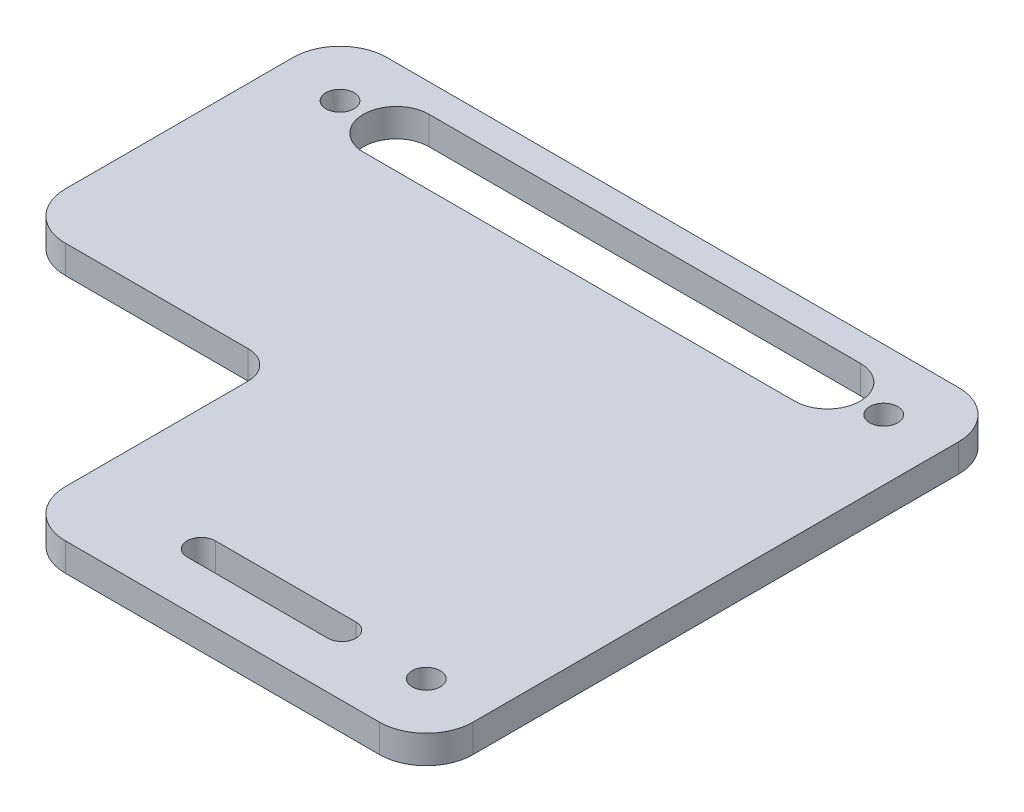
from build123d import *

# Parameters (mm, degrees)
SKETCH_1_W          = 71
SKETCH_1_H          = 61.8
EXTRUDE_1_DEPTH     = 3
FILLET_1_R          = 5
FILLET_3_R          = 5
FILLET_4_R          = 5
SKETCH_2_R          = 1.5
CUT_EXTRUDE_1_DEPTH = 4
CUT_EXTRUDE_2_DEPTH = 4
SKETCH_6_W          = 27.5
SKETCH_6_H          = 27.5
CUT_EXTRUDE_3_DEPTH = 4
FILLET_5_R          = 5
FILLET_6_R          = 3
CUT_EXTRUDE_4_DEPTH = 4


with BuildPart() as part:
    # 草图1 → 凸台-拉伸1 (new body)
    with BuildSketch(Plane(origin=(0, 0, 0), x_dir=(1, 0, 0), z_dir=(0, 1, 0))):
        with Locations((-1.407488987, -9.162114537)):
            Rectangle(SKETCH_1_W, SKETCH_1_H)
    extrude(amount=EXTRUDE_1_DEPTH)

    # 圆角1
    fillet_1_edges = [part.edges().sort_by_distance(p)[0] for p in [
        (-36.907488987, 1.5, -21.737885463),
    ]]
    fillet(fillet_1_edges, radius=FILLET_1_R)

    # 圆角3
    fillet_3_edges = [part.edges().sort_by_distance(p)[0] for p in [
        (34.092511013, 1.5, 40.062114537),
    ]]
    fillet(fillet_3_edges, radius=FILLET_3_R)

    # 圆角4
    fillet_4_edges = [part.edges().sort_by_distance(p)[0] for p in [
        (34.092511013, 1.5, -21.737885463),
    ]]
    fillet(fillet_4_edges, radius=FILLET_4_R)

    # 草图2 → 切除-拉伸1 (cut, through all)
    with BuildSketch(Plane(origin=(0, 0, 0), x_dir=(-1, 0, 0), z_dir=(0, -1, 0))):
        with Locations((30.407488987, 15.237885463)):
            Circle(SKETCH_2_R)
        with Locations((-27.592511013, -33.562114537)):
            Circle(SKETCH_2_R)
        with Locations((-27.592511013, 15.237885463)):
            Circle(SKETCH_2_R)
    extrude(amount=-CUT_EXTRUDE_1_DEPTH, mode=Mode.SUBTRACT)

    # 草图5 → 切除-拉伸2 (cut, through all)
    with BuildSketch(Plane(origin=(0, 0, 0), x_dir=(-1, 0, 0), z_dir=(0, -1, 0))):
        with BuildLine():
            Line((24.407488987, 11.737885463), (-21.592511013, 11.737885463))
            ThreePointArc((-21.592511013, 11.737885463), (-25.092511013, 15.237885463), (-21.592511013, 18.737885463))
            Line((-21.592511013, 18.737885463), (24.407488987, 18.737885463))
            ThreePointArc((24.407488987, 18.737885463), (27.907488987, 15.237885463), (24.407488987, 11.737885463))
        make_face()
    extrude(amount=-CUT_EXTRUDE_2_DEPTH, mode=Mode.SUBTRACT)

    # 草图6 → 切除-拉伸3 (cut, through all)
    with BuildSketch(Plane.XZ):
        with Locations((-23.157488987, 26.312114537)):
            Rectangle(SKETCH_6_W, SKETCH_6_H)
    extrude(amount=-CUT_EXTRUDE_3_DEPTH, mode=Mode.SUBTRACT)

    # 圆角5
    fillet_5_edges = [part.edges().sort_by_distance(p)[0] for p in [
        (-36.907488987, 1.5, 12.562114537),
        (-9.407488987, 1.5, 40.062114537),
    ]]
    fillet(fillet_5_edges, radius=FILLET_5_R)

    # 圆角6
    fillet_6_edges = [part.edges().sort_by_distance(p)[0] for p in [
        (-9.407488987, 1.5, 12.562114537),
    ]]
    fillet(fillet_6_edges, radius=FILLET_6_R)

    # 草图7 → 切除-拉伸4 (cut, through all)
    with BuildSketch(Plane.XZ):
        with BuildLine():
            Line((3.592511013, 35.062114537), (18.592511013, 35.062114537))
            ThreePointArc((18.592511013, 35.062114537), (20.092511013, 33.562114537), (18.592511013, 32.062114537))
            Line((18.592511013, 32.062114537), (3.592511013, 32.062114537))
            ThreePointArc((3.592511013, 32.062114537), (2.092511013, 33.562114537), (3.592511013, 35.062114537))
        make_face()
    extrude(amount=-CUT_EXTRUDE_4_DEPTH, mode=Mode.SUBTRACT)


solid = part.part
